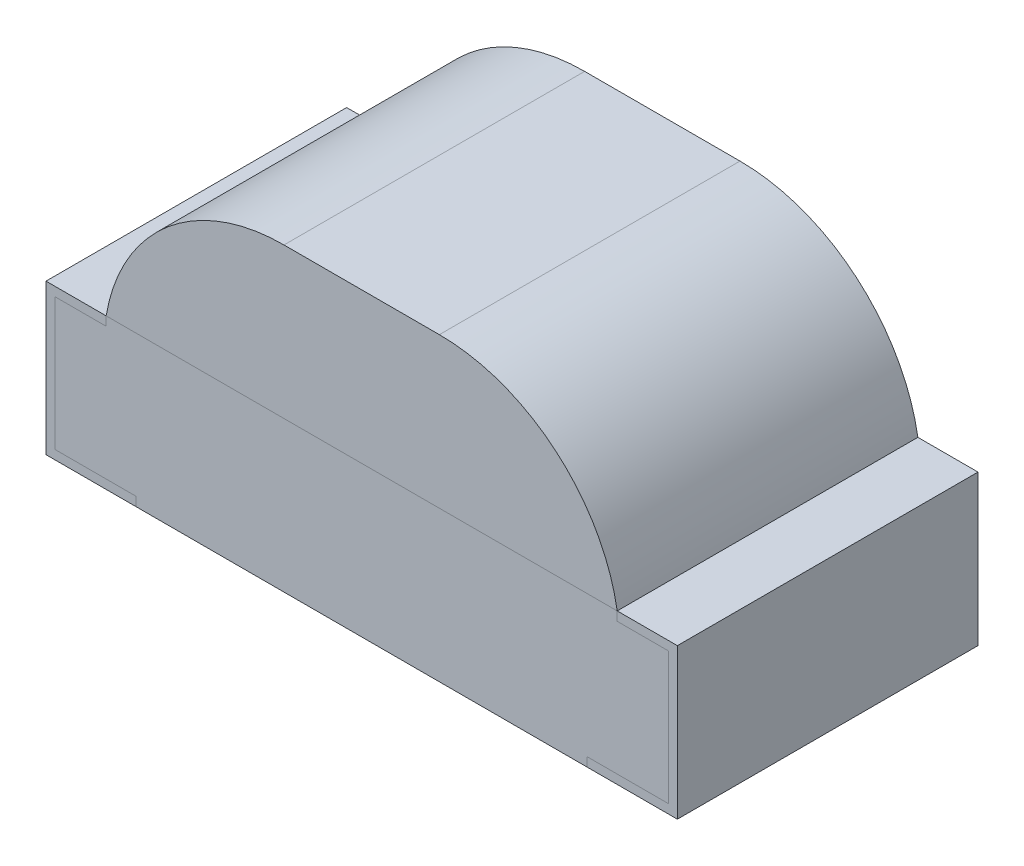
from build123d import *

# Parameters (mm, degrees)
EXTRUDE1_DEPTH     = 0.5
EXTRUDE3_DEPTH     = 0.5
EXTRUDE3_2_DEPTH   = 0.5
EXTRUDE6_DEPTH     = 0.5
SKETCH6_W          = 0.013291139
SKETCH6_H          = 0.012658227
SKETCH6_H_2        = 0.012658228
CUT_EXTRUDE1_DEPTH = 0.01


with BuildPart() as part:
    # Sketch1 → Extrude1 (new body, symmetric)
    with BuildSketch(Plane.XY):
        Polygon((0.85, 0.25), (-0.85, 0.25), (-0.85, 0.22), (-1.02, 0.22), (-1.02, -0.22), (-0.75, -0.22), (-0.75, -0.25), (0.75, -0.25), (0.75, -0.22), (1.02, -0.22), (1.02, 0.22), (0.85, 0.22), align=None)
    extrude(amount=EXTRUDE1_DEPTH, both=True)


with BuildPart() as body_2:
    # Sketch1_6 → Extrude3 (new body, symmetric)
    with BuildSketch(Plane.XY):
        Polygon((-0.85, 0.25), (-1.05, 0.25), (-1.05, -0.25), (-0.75, -0.25), (-0.75, -0.22), (-1.02, -0.22), (-1.02, 0.22), (-0.85, 0.22), align=None)
    extrude(amount=EXTRUDE3_DEPTH, both=True)


with BuildPart() as body_3:
    # Sketch1_6 → Extrude3 2 (new body, symmetric)
    with BuildSketch(Plane.XY):
        Polygon((1.05, 0.25), (0.85, 0.25), (0.85, 0.22), (1.02, 0.22), (1.02, -0.22), (0.75, -0.22), (0.75, -0.25), (1.05, -0.25), align=None)
    extrude(amount=EXTRUDE3_2_DEPTH, both=True)

    # Sketch6 → Cut-Extrude1 (cut)
    with BuildSketch(Plane.XZ.offset(0.25)):
        Polygon((0.942023927, -0.286075949), (0.979365699, -0.297804589), (0.979365699, -0.310176028), (0.954197582, -0.318384098), (0.979365699, -0.326147152), (0.979365699, -0.339013054), (0.942023927, -0.350632911), (0.942023927, -0.338043908), (0.96776562, -0.331546677), (0.942023927, -0.323338608), (0.942023927, -0.312589003), (0.96776562, -0.30443038), (0.942023927, -0.298022152), align=None)
        Polygon((0.942023927, -0.218987342), (0.979365699, -0.230715981), (0.979365699, -0.243087421), (0.954197582, -0.251295491), (0.979365699, -0.259058544), (0.979365699, -0.271924446), (0.942023927, -0.283544304), (0.942023927, -0.270955301), (0.96776562, -0.26445807), (0.942023927, -0.25625), (0.942023927, -0.245500396), (0.96776562, -0.237341772), (0.942023927, -0.230933544), align=None)
        Polygon((0.942023927, -0.151898734), (0.979365699, -0.163627373), (0.979365699, -0.175998813), (0.954197582, -0.184206883), (0.979365699, -0.191969937), (0.979365699, -0.204835839), (0.942023927, -0.216455696), (0.942023927, -0.203866693), (0.96776562, -0.197369462), (0.942023927, -0.189161392), (0.942023927, -0.178411788), (0.96776562, -0.170253165), (0.942023927, -0.163844937), align=None)
        with Locations((0.97272013, -0.137974684)):
            Rectangle(SKETCH6_W, SKETCH6_H)
        with BuildLine():
            add(Edge.make_bspline(
                [(0.963780256, -0.079746835), (0.964391317, -0.079765095), (0.965591237, -0.07980095), (0.967345165, -0.080105597), (0.969007007, -0.080603118), (0.970587626, -0.081286176), (0.972069839, -0.082190859), (0.973467847, -0.083281511), (0.974774946, -0.084575265), (0.97597921, -0.086053455), (0.977081541, -0.087694003), (0.978027094, -0.089495243), (0.978840362, -0.091429741), (0.97950595, -0.093506939), (0.980001407, -0.095729674), (0.980363044, -0.098088578), (0.980599804, -0.100585248), (0.980620774, -0.102297042), (0.980631522, -0.103174446)],
                knots=[0, 0, 0, 0, 0.907462679, 1.781953809, 2.635804048, 3.480274448, 4.332887508, 5.208817748, 6.109340518, 7.059474472, 8.037577805, 9.041105121, 10.077237313, 11.152245627, 12.27748741, 13.457227022, 14.696666784, 16, 16, 16, 16], degree=3))
            add(Edge.make_bspline(
                [(0.980631522, -0.103174446), (0.98061789, -0.104183438), (0.980591488, -0.106137532), (0.980398801, -0.108971316), (0.980054827, -0.111603049), (0.979576536, -0.114051922), (0.978974894, -0.116354073), (0.978329572, -0.118570745), (0.977597282, -0.120711391), (0.977047213, -0.122097937), (0.976774718, -0.12278481)],
                knots=[0, 0, 0, 0, 1.203182053, 2.33017619, 3.384818652, 4.366208123, 5.30340534, 6.221361684, 7.118890722, 8, 8, 8, 8], degree=3))
            Line((0.976774718, -0.12278481), (0.964808737, -0.12278481))
            Line((0.964808737, -0.12278481), (0.964808737, -0.121360759))
            add(Edge.make_bspline(
                [(0.964808737, -0.121360759), (0.965349219, -0.120677978), (0.966427008, -0.119316423), (0.967811185, -0.117102944), (0.968997691, -0.114773438), (0.969989002, -0.112354241), (0.970776809, -0.109903557), (0.971340262, -0.107469023), (0.971709944, -0.105084532), (0.971750725, -0.103505371), (0.971770763, -0.10272943)],
                knots=[0, 0, 0, 0, 1.030738938, 2.055426519, 3.085610749, 4.123842265, 5.148648843, 6.130724483, 7.081507926, 8, 8, 8, 8], degree=3))
            add(Edge.make_bspline(
                [(0.971770763, -0.10272943), (0.971770095, -0.102515059), (0.971768664, -0.102056106), (0.971708608, -0.101324778), (0.971643408, -0.100500017), (0.971546409, -0.099612821), (0.971429223, -0.098716237), (0.971258632, -0.097882287), (0.971072578, -0.097128904), (0.970889029, -0.096675553), (0.970801617, -0.096459652)],
                knots=[0, 0, 0, 0, 0.806557331, 1.726776592, 2.760222249, 3.920734434, 5.085813889, 6.161303184, 7.124353598, 8, 8, 8, 8], degree=3))
            add(Edge.make_bspline(
                [(0.970801617, -0.096459652), (0.970687341, -0.096220023), (0.970462763, -0.095749102), (0.970059431, -0.095098444), (0.969606025, -0.094520783), (0.969125331, -0.09399241), (0.968550008, -0.093549248), (0.967846406, -0.093240817), (0.967022414, -0.093067634), (0.966434735, -0.093048233), (0.966124006, -0.093037975)],
                knots=[0, 0, 0, 0, 1.025060442, 2.01446193, 2.949256246, 3.85908539, 4.768290539, 5.73153362, 6.800575992, 8, 8, 8, 8], degree=3))
            add(Edge.make_bspline(
                [(0.966124006, -0.093037975), (0.965851203, -0.093053907), (0.96531479, -0.093085234), (0.964547015, -0.093373687), (0.963843309, -0.093828987), (0.963206604, -0.094465973), (0.962647468, -0.095272368), (0.962136146, -0.096231159), (0.961721689, -0.097366685), (0.961502393, -0.098185091), (0.96138706, -0.098615506)],
                knots=[0, 0, 0, 0, 0.825786558, 1.623739628, 2.456775365, 3.355767579, 4.339087636, 5.42728423, 6.646958453, 8, 8, 8, 8], degree=3))
            add(Edge.make_bspline(
                [(0.96138706, -0.098615506), (0.961164205, -0.099600075), (0.960706836, -0.101620729), (0.960117289, -0.104691497), (0.959499962, -0.107759915), (0.958894253, -0.109735067), (0.958598294, -0.110700158)],
                knots=[0, 0, 0, 0, 0.976116373, 2.003306214, 3.02438349, 4, 4, 4, 4], degree=3))
            add(Edge.make_bspline(
                [(0.958598294, -0.110700158), (0.958421434, -0.111219236), (0.958077159, -0.112229669), (0.957500818, -0.113679248), (0.956848312, -0.11500093), (0.956187082, -0.116229502), (0.955447781, -0.117326516), (0.954677409, -0.118323373), (0.95385793, -0.119209525), (0.952979238, -0.11997228), (0.952061704, -0.120644504), (0.951087596, -0.121220017), (0.950056938, -0.121704075), (0.948974709, -0.122100291), (0.947840079, -0.122409707), (0.946651444, -0.122619779), (0.945409819, -0.122769127), (0.944562635, -0.122779511), (0.944130335, -0.12278481)],
                knots=[0, 0, 0, 0, 1.287139616, 2.505537848, 3.65787682, 4.745319116, 5.777517297, 6.75878323, 7.700384896, 8.605120322, 9.485712598, 10.366814604, 11.256335458, 12.154696155, 13.068779358, 14.012730507, 14.985940713, 16, 16, 16, 16], degree=3))
            add(Edge.make_bspline(
                [(0.944130335, -0.12278481), (0.943552262, -0.12276616), (0.942414625, -0.122729457), (0.940750114, -0.122428732), (0.939175704, -0.121915476), (0.937674126, -0.121222297), (0.936266995, -0.12030855), (0.934928251, -0.119212489), (0.933682003, -0.117907334), (0.932532685, -0.11641467), (0.931493282, -0.114771246), (0.930574929, -0.113004244), (0.929821705, -0.111114818), (0.929181089, -0.109124876), (0.928704892, -0.107015179), (0.928345103, -0.104796694), (0.928138602, -0.102459763), (0.928112965, -0.100864057), (0.928099877, -0.100049446)],
                knots=[0, 0, 0, 0, 0.894901293, 1.761149761, 2.608783409, 3.453876344, 4.314933854, 5.200038827, 6.12799933, 7.103249695, 8.113098521, 9.136064399, 10.182719798, 11.259667356, 12.370545059, 13.528828137, 14.738461593, 16, 16, 16, 16], degree=3))
            add(Edge.make_bspline(
                [(0.928099877, -0.100049446), (0.928111054, -0.099215117), (0.928133389, -0.097547873), (0.92832116, -0.095056937), (0.92860296, -0.092581272), (0.929006451, -0.090146191), (0.929511182, -0.087804125), (0.930055906, -0.085592886), (0.930675869, -0.083553353), (0.93115292, -0.082266497), (0.931383104, -0.08164557)],
                knots=[0, 0, 0, 0, 1.065384654, 2.128962885, 3.18847586, 4.246683315, 5.279600907, 6.247539799, 7.154412252, 8, 8, 8, 8], degree=3))
            Line((0.931383104, -0.08164557), (0.942656839, -0.08164557))
            Line((0.942656839, -0.08164557), (0.942656839, -0.083059731))
            add(Edge.make_bspline(
                [(0.942656839, -0.083059731), (0.942257266, -0.08359651), (0.941441829, -0.084691955), (0.940389812, -0.086516316), (0.939423961, -0.088503046), (0.938559296, -0.090636887), (0.93784973, -0.092873533), (0.937335013, -0.095162206), (0.937015502, -0.097475764), (0.936978929, -0.099026556), (0.936960636, -0.099802215)],
                knots=[0, 0, 0, 0, 0.892231706, 1.82084296, 2.804411717, 3.838445872, 4.890103822, 5.931567007, 6.965432763, 8, 8, 8, 8], degree=3))
            add(Edge.make_bspline(
                [(0.936960636, -0.099802215), (0.93697296, -0.100349834), (0.936997673, -0.101447923), (0.937169413, -0.103085623), (0.937509265, -0.10470221), (0.937914818, -0.105720746), (0.938117677, -0.106230222)],
                knots=[0, 0, 0, 0, 0.99896713, 2.003134239, 3.001159596, 4, 4, 4, 4], degree=3))
            add(Edge.make_bspline(
                [(0.938117677, -0.106230222), (0.938218275, -0.106447074), (0.938419402, -0.106880635), (0.938809098, -0.107484586), (0.939267718, -0.108044383), (0.93979435, -0.108546656), (0.940384884, -0.108958725), (0.941016219, -0.109279365), (0.941697686, -0.109459079), (0.942164706, -0.109482091), (0.942399718, -0.109493671)],
                knots=[0, 0, 0, 0, 1.005120364, 2.009570296, 3.014977851, 4.045438181, 5.061509448, 6.035608779, 7.011484765, 8, 8, 8, 8], degree=3))
            add(Edge.make_bspline(
                [(0.942399718, -0.109493671), (0.942718684, -0.109476274), (0.943328198, -0.109443029), (0.944185046, -0.109143031), (0.944916602, -0.108644196), (0.945413099, -0.108067647), (0.945762478, -0.107509157), (0.946015098, -0.106988898), (0.94627181, -0.106389173), (0.946516408, -0.105700449), (0.946763431, -0.104932881), (0.947000766, -0.10407842), (0.947225546, -0.103137116), (0.947368622, -0.102479171), (0.947443231, -0.102136076)],
                knots=[0, 0, 0, 0, 1.174343879, 2.244064321, 3.303704314, 4.407076671, 5.02483983, 5.732197225, 6.53898402, 7.431906431, 8.428480183, 9.514816237, 10.704066255, 12, 12, 12, 12], degree=3))
            add(Edge.make_bspline(
                [(0.947443231, -0.102136076), (0.947631281, -0.101219696), (0.94800011, -0.099422374), (0.948551726, -0.096720829), (0.949203157, -0.093973178), (0.949769353, -0.092134993), (0.95006388, -0.091178797)],
                knots=[0, 0, 0, 0, 0.995794372, 1.953081347, 2.935223864, 4, 4, 4, 4], degree=3))
            add(Edge.make_bspline(
                [(0.95006388, -0.091178797), (0.950223558, -0.090705552), (0.950535914, -0.089779808), (0.951078274, -0.088459051), (0.951669256, -0.087234467), (0.952280719, -0.086095531), (0.952961565, -0.085063797), (0.95367023, -0.084121379), (0.954423217, -0.083272798), (0.955230894, -0.082528232), (0.956086232, -0.081864231), (0.957011058, -0.081306729), (0.95798564, -0.080813421), (0.959025857, -0.080417612), (0.960131338, -0.080125373), (0.96129478, -0.079909034), (0.962517356, -0.079763429), (0.963354591, -0.079752429), (0.963780256, -0.079746835)],
                knots=[0, 0, 0, 0, 1.237247399, 2.420255609, 3.534416354, 4.605351393, 5.620193117, 6.593738998, 7.524982051, 8.426564095, 9.311945829, 10.20281032, 11.097671666, 12.01534975, 12.954438892, 13.926750701, 14.945921247, 16, 16, 16, 16], degree=3))
        make_face()
        with BuildLine():
            Line((0.979365699, -0.033544304), (0.979365699, -0.04556962))
            Line((0.979365699, -0.04556962), (0.97544956, -0.04556962))
            add(Edge.make_bspline(
                [(0.97544956, -0.04556962), (0.975854012, -0.046116191), (0.976633789, -0.047169971), (0.977671595, -0.048757603), (0.978567758, -0.050268087), (0.97932077, -0.051737301), (0.979934597, -0.053237003), (0.980340675, -0.054854082), (0.980592715, -0.056604595), (0.980618299, -0.057818171), (0.980631522, -0.058445411)],
                knots=[0, 0, 0, 0, 1.15097647, 2.219065785, 3.209751872, 4.123278731, 5.012494873, 5.946522673, 6.938654008, 8, 8, 8, 8], degree=3))
            add(Edge.make_bspline(
                [(0.980631522, -0.058445411), (0.980620043, -0.058953546), (0.98059769, -0.05994303), (0.9804269, -0.061382224), (0.980152449, -0.06273305), (0.979769108, -0.063998021), (0.979263402, -0.065173533), (0.978638053, -0.066252373), (0.977907119, -0.067245707), (0.977068992, -0.068147533), (0.976108418, -0.068942805), (0.975047068, -0.069636341), (0.973879742, -0.070224244), (0.972604061, -0.070695064), (0.971224838, -0.07107253), (0.969735235, -0.071334519), (0.968141665, -0.071494809), (0.967044101, -0.071510779), (0.966480019, -0.071518987)],
                knots=[0, 0, 0, 0, 1.108887696, 2.159324556, 3.158383213, 4.114277414, 5.039206009, 5.945047284, 6.830075132, 7.726032535, 8.625162295, 9.545152215, 10.487958828, 11.471559655, 12.508379831, 13.604991163, 14.769110247, 16, 16, 16, 16], degree=3))
            Line((0.966480019, -0.071518987), (0.942023927, -0.071518987))
            Line((0.942023927, -0.071518987), (0.942023927, -0.059493671))
            Line((0.942023927, -0.059493671), (0.960813484, -0.059493671))
            add(Edge.make_bspline(
                [(0.960813484, -0.059493671), (0.96127172, -0.059492853), (0.962148828, -0.059491288), (0.963401731, -0.059450118), (0.964535817, -0.059389668), (0.965556831, -0.059320316), (0.966480207, -0.059193807), (0.967313287, -0.059004953), (0.968073088, -0.05876954), (0.968526439, -0.058537381), (0.968744655, -0.058425633)],
                knots=[0, 0, 0, 0, 1.361401701, 2.605856924, 3.723918663, 4.735739235, 5.645738665, 6.489217889, 7.27279937, 8, 8, 8, 8], degree=3))
            add(Edge.make_bspline(
                [(0.968744655, -0.058425633), (0.968943974, -0.058310612), (0.969335819, -0.058084491), (0.969839459, -0.057624598), (0.970257655, -0.057086557), (0.970595005, -0.056451936), (0.970832585, -0.055703876), (0.971026175, -0.054841422), (0.971111284, -0.053845226), (0.971128655, -0.053141541), (0.971137851, -0.052768987)],
                knots=[0, 0, 0, 0, 0.848923305, 1.668910138, 2.502822694, 3.358979167, 4.311113223, 5.396624103, 6.621686681, 8, 8, 8, 8], degree=3))
            add(Edge.make_bspline(
                [(0.971137851, -0.052768987), (0.971127877, -0.052498527), (0.971107384, -0.051942841), (0.971012868, -0.051087147), (0.970810789, -0.050196327), (0.970488804, -0.04893715), (0.969895322, -0.047349804), (0.969216559, -0.046167616), (0.968873215, -0.04556962)],
                knots=[0, 0, 0, 0, 0.638098464, 1.31103257, 2.025970928, 2.789492669, 4.376004971, 6, 6, 6, 6], degree=3))
            Line((0.968873215, -0.04556962), (0.942023927, -0.04556962))
            Line((0.942023927, -0.04556962), (0.942023927, -0.033544304))
            Line((0.942023927, -0.033544304), (0.979365699, -0.033544304))
        make_face()
        with BuildLine():
            Line((0.979365699, 0.015189873), (0.979365699, 0.003164557))
            Line((0.979365699, 0.003164557), (0.960576142, 0.003164557))
            add(Edge.make_bspline(
                [(0.960576142, 0.003164557), (0.959810931, 0.003154152), (0.958281489, 0.003133354), (0.956402788, 0.002969251), (0.954979251, 0.002799515), (0.954064375, 0.002612137), (0.953290217, 0.002396966), (0.952847347, 0.002190751), (0.952644972, 0.002096519)],
                knots=[0, 0, 0, 0, 1.709225407, 3.416259723, 4.21101956, 4.910102269, 5.501957085, 6, 6, 6, 6], degree=3))
            add(Edge.make_bspline(
                [(0.952644972, 0.002096519), (0.952445906, 0.001974306), (0.952055609, 0.001734689), (0.951549666, 0.001265768), (0.951131294, 0.000717495), (0.95079987, 7.7929e-05), (0.950552666, -0.000662865), (0.950379525, -0.00152278), (0.950273413, -0.002512547), (0.950259263, -0.00321701), (0.950251775, -0.003589794)],
                knots=[0, 0, 0, 0, 0.860284341, 1.686708632, 2.528476982, 3.393563585, 4.332150703, 5.400907339, 6.624626855, 8, 8, 8, 8], degree=3))
            add(Edge.make_bspline(
                [(0.950251775, -0.003589794), (0.950281748, -0.004155273), (0.95034291, -0.005309189), (0.950677276, -0.006746396), (0.951103891, -0.007903214), (0.951486848, -0.008828607), (0.951965498, -0.009786415), (0.952328843, -0.010428192), (0.952516411, -0.010759494)],
                knots=[0, 0, 0, 0, 1.338233385, 2.730803257, 3.468495571, 4.255080394, 5.099229486, 6, 6, 6, 6], degree=3))
            Line((0.952516411, -0.010759494), (0.979365699, -0.010759494))
            Line((0.979365699, -0.010759494), (0.979365699, -0.02278481))
            Line((0.979365699, -0.02278481), (0.942023927, -0.02278481))
            Line((0.942023927, -0.02278481), (0.942023927, -0.010759494))
            Line((0.942023927, -0.010759494), (0.945940066, -0.010759494))
            add(Edge.make_bspline(
                [(0.945940066, -0.010759494), (0.945536848, -0.010230875), (0.944751958, -0.009201887), (0.943735253, -0.007613511), (0.942830325, -0.006078155), (0.942074258, -0.004550894), (0.941474958, -0.002988645), (0.941067156, -0.00135483), (0.940795682, 0.000353526), (0.940770776, 0.001521863), (0.940758104, 0.002116297)],
                knots=[0, 0, 0, 0, 1.126064518, 2.191951536, 3.19307265, 4.144813015, 5.076393104, 6.021983703, 6.993610568, 8, 8, 8, 8], degree=3))
            add(Edge.make_bspline(
                [(0.940758104, 0.002116297), (0.940770805, 0.00261443), (0.940795598, 0.003586873), (0.940950374, 0.005004298), (0.941225985, 0.006339851), (0.941623913, 0.007586544), (0.942119593, 0.008754385), (0.942721581, 0.009841227), (0.94345323, 0.010834129), (0.944283169, 0.011748289), (0.945228932, 0.012567521), (0.946293178, 0.013267202), (0.947464422, 0.013865138), (0.948739194, 0.014358798), (0.950128673, 0.014734317), (0.951625363, 0.014992409), (0.953230812, 0.015169548), (0.954338815, 0.015182963), (0.954909608, 0.015189873)],
                knots=[0, 0, 0, 0, 1.088244909, 2.124447647, 3.110254678, 4.062235362, 4.978491991, 5.877983887, 6.769571508, 7.666696544, 8.570415953, 9.495151274, 10.442024977, 11.43832337, 12.476026402, 13.580659577, 14.753665747, 16, 16, 16, 16], degree=3))
            Line((0.954909608, 0.015189873), (0.979365699, 0.015189873))
        make_face()
        Polygon((0.979365699, 0.062658228), (0.979365699, 0.026582278), (0.929365699, 0.026582278), (0.929365699, 0.039240506), (0.969872029, 0.039240506), (0.969872029, 0.062658228), align=None)
        Polygon((0.979365699, 0.106329114), (0.979365699, 0.070253165), (0.929365699, 0.070253165), (0.929365699, 0.106329114), (0.93885937, 0.106329114), (0.93885937, 0.082911392), (0.94772013, 0.082911392), (0.94772013, 0.10443038), (0.957213801, 0.10443038), (0.957213801, 0.082911392), (0.969872029, 0.082911392), (0.969872029, 0.106329114), align=None)
        with BuildLine():
            add(Edge.make_bspline(
                [(0.954415146, 0.164556962), (0.95498899, 0.164547304), (0.956125433, 0.164528178), (0.957807836, 0.164380583), (0.959440674, 0.16411757), (0.961032798, 0.163777979), (0.962572262, 0.163316726), (0.964076051, 0.16277587), (0.965528798, 0.162121047), (0.966929515, 0.16136862), (0.968265566, 0.160543884), (0.969525671, 0.15965651), (0.97071728, 0.15873362), (0.971814726, 0.157738964), (0.972835736, 0.156699373), (0.973781143, 0.155611609), (0.974632859, 0.154459076), (0.975144301, 0.153655495), (0.975400114, 0.15325356)],
                knots=[0, 0, 0, 0, 1.105570398, 2.18947457, 3.250358341, 4.290584537, 5.323553275, 6.344225964, 7.367641686, 8.3905646, 9.405808457, 10.390761353, 11.358902336, 12.307789878, 13.241960776, 14.165076779, 15.082208636, 16, 16, 16, 16], degree=3))
            add(Edge.make_bspline(
                [(0.975400114, 0.15325356), (0.975756289, 0.15263397), (0.976470457, 0.151391629), (0.977303153, 0.149399346), (0.978012171, 0.147335712), (0.978515776, 0.145152055), (0.978901516, 0.14283301), (0.979176757, 0.140333989), (0.979328806, 0.137633765), (0.979353121, 0.135766275), (0.979365699, 0.134800237)],
                knots=[0, 0, 0, 0, 0.896331627, 1.797236794, 2.705411718, 3.632841792, 4.606367508, 5.655603524, 6.787262262, 8, 8, 8, 8], degree=3))
            Line((0.979365699, 0.134800237), (0.979365699, 0.117088608))
            Line((0.979365699, 0.117088608), (0.929365699, 0.117088608))
            Line((0.929365699, 0.117088608), (0.929365699, 0.135304589))
            add(Edge.make_bspline(
                [(0.929365699, 0.135304589), (0.929374147, 0.136293933), (0.92939044, 0.138202255), (0.929597095, 0.140957702), (0.929901305, 0.14350546), (0.93034931, 0.145849866), (0.930903253, 0.148005294), (0.931599487, 0.149966708), (0.93234558, 0.151774882), (0.932982883, 0.152864142), (0.933291728, 0.153392009)],
                knots=[0, 0, 0, 0, 1.267100211, 2.444079055, 3.537724964, 4.552266402, 5.499704501, 6.385138932, 7.217420793, 8, 8, 8, 8], degree=3))
            add(Edge.make_bspline(
                [(0.933291728, 0.153392009), (0.933559998, 0.153817486), (0.934093455, 0.154663548), (0.934984381, 0.155864156), (0.93596242, 0.156978869), (0.936988329, 0.158043121), (0.938089773, 0.159033028), (0.939259125, 0.159954635), (0.940498178, 0.160806518), (0.941802888, 0.161585596), (0.943168008, 0.162295638), (0.94460418, 0.162891678), (0.946095617, 0.163411359), (0.947645087, 0.1638344), (0.949253782, 0.164162565), (0.950922522, 0.164385607), (0.952649116, 0.164527324), (0.953821513, 0.164546999), (0.954415146, 0.164556962)],
                knots=[0, 0, 0, 0, 0.964043478, 1.917004671, 2.862223898, 3.805158963, 4.749279098, 5.698713747, 6.657523689, 7.629652222, 8.610369353, 9.604453025, 10.607693792, 11.636365947, 12.681120053, 13.752669011, 14.862083412, 16, 16, 16, 16], degree=3))
        make_face()
        with BuildLine():
            add(Edge.make_bspline(
                [(0.954336032, 0.151265823), (0.953547104, 0.151242622), (0.95202427, 0.151197838), (0.949822169, 0.150866066), (0.947805536, 0.150276301), (0.946247285, 0.149611683), (0.945110777, 0.14894241), (0.944311611, 0.148378763), (0.94355452, 0.1477539), (0.942850098, 0.147058603), (0.94219658, 0.146291009), (0.941582125, 0.14546038), (0.941017802, 0.14456036), (0.940687799, 0.143923844), (0.940520763, 0.143601661)],
                knots=[0, 0, 0, 0, 1.694561208, 3.270940604, 4.767926833, 6.198032689, 6.896357436, 7.597727349, 8.296769799, 9.00280713, 9.720956486, 10.460265288, 11.220639329, 12, 12, 12, 12], degree=3))
            add(Edge.make_bspline(
                [(0.940520763, 0.143601661), (0.940367506, 0.143264194), (0.940063739, 0.14259531), (0.939696696, 0.141560172), (0.939415532, 0.140513821), (0.939179321, 0.139416708), (0.939040753, 0.138178328), (0.938934415, 0.136717082), (0.938865951, 0.134988745), (0.938861666, 0.133745448), (0.93885937, 0.133079509)],
                knots=[0, 0, 0, 0, 0.826913061, 1.638999358, 2.447478739, 3.243919028, 4.140906711, 5.225381046, 6.513851968, 8, 8, 8, 8], degree=3))
            Line((0.93885937, 0.133079509), (0.93885937, 0.129746835))
            Line((0.93885937, 0.129746835), (0.969872029, 0.129746835))
            Line((0.969872029, 0.129746835), (0.969872029, 0.133079509))
            add(Edge.make_bspline(
                [(0.969872029, 0.133079509), (0.969869508, 0.133458605), (0.969864641, 0.134190473), (0.969845064, 0.135248697), (0.96981499, 0.136231088), (0.969778791, 0.137134731), (0.969722466, 0.137959632), (0.969635471, 0.138703229), (0.969567122, 0.139371634), (0.96942856, 0.140157893), (0.969225436, 0.141085478), (0.968883901, 0.142168875), (0.968459102, 0.143239224), (0.968116564, 0.143933499), (0.967943627, 0.144284019)],
                knots=[0, 0, 0, 0, 1.186788252, 2.291168447, 3.31326867, 4.263560303, 5.122314491, 5.900668105, 6.60723418, 7.224768558, 8.398927205, 9.577205322, 10.776800932, 12, 12, 12, 12], degree=3))
            add(Edge.make_bspline(
                [(0.967943627, 0.144284019), (0.967771888, 0.144575875), (0.967434144, 0.145149841), (0.966881224, 0.14597193), (0.966263682, 0.146715236), (0.965622287, 0.1474185), (0.964926497, 0.14804408), (0.964204727, 0.148632729), (0.963417456, 0.14912535), (0.962322988, 0.149749785), (0.96080941, 0.150371573), (0.958823448, 0.15088838), (0.956643871, 0.151207776), (0.955125018, 0.151245978), (0.954336032, 0.151265823)],
                knots=[0, 0, 0, 0, 0.755184287, 1.485151634, 2.206180267, 2.908413556, 3.605665444, 4.291074465, 4.982332562, 5.673512475, 7.100235687, 8.614142391, 10.24117603, 12, 12, 12, 12], degree=3))
        make_face(mode=Mode.SUBTRACT)
        with Locations((0.97272013, 0.180379747)):
            Rectangle(SKETCH6_W, SKETCH6_H_2)
        with BuildLine():
            add(Edge.make_bspline(
                [(0.980631522, 0.217701741), (0.980620613, 0.216906686), (0.9805992, 0.215346121), (0.980360794, 0.213060425), (0.980001758, 0.210877928), (0.97949197, 0.208804458), (0.978817283, 0.206852816), (0.977999747, 0.205016624), (0.976999828, 0.20331702), (0.976208519, 0.202283529), (0.975815462, 0.201770174)],
                knots=[0, 0, 0, 0, 1.123640227, 2.2055255, 3.245221982, 4.248949655, 5.220213072, 6.160941522, 7.086505793, 8, 8, 8, 8], degree=3))
            add(Edge.make_bspline(
                [(0.975815462, 0.201770174), (0.975388046, 0.201294357), (0.974534865, 0.200344562), (0.973049594, 0.199110748), (0.971405107, 0.19805171), (0.969609281, 0.197145583), (0.967649338, 0.196429607), (0.965524391, 0.195933339), (0.963245726, 0.195619537), (0.961671624, 0.195586562), (0.96086293, 0.19556962)],
                knots=[0, 0, 0, 0, 0.916342154, 1.829140869, 2.758848968, 3.716597128, 4.708179637, 5.743612459, 6.840783343, 8, 8, 8, 8], degree=3))
            add(Edge.make_bspline(
                [(0.96086293, 0.19556962), (0.960011317, 0.195589), (0.958360777, 0.195626562), (0.955974683, 0.195958442), (0.953765843, 0.196493248), (0.951739889, 0.197262027), (0.949893293, 0.198227248), (0.948207375, 0.199359494), (0.946685913, 0.200669757), (0.945813194, 0.201673326), (0.94537638, 0.202175633)],
                knots=[0, 0, 0, 0, 1.171797512, 2.271099083, 3.308930235, 4.294129479, 5.24602549, 6.17106565, 7.084581485, 8, 8, 8, 8], degree=3))
            add(Edge.make_bspline(
                [(0.94537638, 0.202175633), (0.944992053, 0.202688547), (0.944218757, 0.203720569), (0.943270397, 0.205420009), (0.942471414, 0.207228345), (0.941833934, 0.209139987), (0.941359311, 0.211131338), (0.941011428, 0.213166058), (0.940797357, 0.215238016), (0.940771252, 0.216633199), (0.940758104, 0.217335839)],
                knots=[0, 0, 0, 0, 0.952013349, 1.915525331, 2.885385798, 3.888123097, 4.906830296, 5.926067872, 6.955529031, 8, 8, 8, 8], degree=3))
            add(Edge.make_bspline(
                [(0.940758104, 0.217335839), (0.940766284, 0.217959245), (0.940782367, 0.219185073), (0.940947946, 0.220984436), (0.941197454, 0.222710434), (0.94156924, 0.22436008), (0.942030647, 0.225943178), (0.942542721, 0.227474903), (0.943112676, 0.228957022), (0.943554654, 0.229907399), (0.943774323, 0.230379747)],
                knots=[0, 0, 0, 0, 1.107572103, 2.177862056, 3.208491727, 4.204802822, 5.180069889, 6.137814326, 7.074472616, 8, 8, 8, 8], degree=3))
            Line((0.943774323, 0.230379747), (0.954049244, 0.230379747))
            Line((0.954049244, 0.230379747), (0.954049244, 0.228708465))
            add(Edge.make_bspline(
                [(0.954049244, 0.228708465), (0.953840798, 0.228458567), (0.95338733, 0.227914921), (0.952673887, 0.227024009), (0.951913254, 0.225946553), (0.951468921, 0.225124219), (0.95123081, 0.224683544)],
                knots=[0, 0, 0, 0, 0.792806788, 1.724728901, 2.780722718, 4, 4, 4, 4], degree=3))
            add(Edge.make_bspline(
                [(0.95123081, 0.224683544), (0.951011038, 0.224219215), (0.950558792, 0.223263722), (0.95012665, 0.221990162), (0.949858659, 0.22089), (0.949727647, 0.219986025), (0.949633839, 0.21901897), (0.949623947, 0.218351384), (0.949618864, 0.218008307)],
                knots=[0, 0, 0, 0, 1.332411269, 2.741822805, 3.48048496, 4.268099981, 5.109965479, 6, 6, 6, 6], degree=3))
            add(Edge.make_bspline(
                [(0.949618864, 0.218008307), (0.949628534, 0.217625491), (0.949647275, 0.216883611), (0.949787231, 0.21580338), (0.950021518, 0.21479124), (0.950359639, 0.213846625), (0.950789792, 0.212969345), (0.951299872, 0.21215151), (0.951925867, 0.211413689), (0.952635083, 0.210742876), (0.953430245, 0.21014909), (0.954293514, 0.209635725), (0.955222454, 0.209194359), (0.95622141, 0.208843413), (0.95728634, 0.208564658), (0.958417745, 0.208369875), (0.959617544, 0.208248986), (0.960440692, 0.208235015), (0.96086293, 0.208227848)],
                knots=[0, 0, 0, 0, 1.087164589, 2.106874378, 3.088024391, 4.032801718, 4.949890679, 5.859058447, 6.763003849, 7.690312844, 8.626654282, 9.575690722, 10.539030902, 11.54301425, 12.578634972, 13.662366762, 14.800897888, 16, 16, 16, 16], degree=3))
            add(Edge.make_bspline(
                [(0.96086293, 0.208227848), (0.961295009, 0.208235235), (0.962134515, 0.208249588), (0.96335532, 0.208366345), (0.964496036, 0.208574291), (0.965558696, 0.208859915), (0.966541705, 0.209222089), (0.967440403, 0.209674648), (0.968268807, 0.210192826), (0.969000113, 0.210815105), (0.969658274, 0.211497047), (0.970226341, 0.212254492), (0.970700413, 0.213084112), (0.971102645, 0.213975202), (0.971391844, 0.214941723), (0.97161019, 0.215969991), (0.971754468, 0.217064769), (0.97176525, 0.217819945), (0.971770763, 0.218206092)],
                knots=[0, 0, 0, 0, 1.230336593, 2.390482092, 3.487897344, 4.52859895, 5.520747884, 6.465347575, 7.38981449, 8.296085817, 9.192433006, 10.084246191, 10.984321635, 11.908883871, 12.862027947, 13.850751296, 14.901019963, 16, 16, 16, 16], degree=3))
            add(Edge.make_bspline(
                [(0.971770763, 0.218206092), (0.971766335, 0.218568967), (0.971757704, 0.219276378), (0.971653983, 0.220306739), (0.971498788, 0.221281952), (0.971277972, 0.222198087), (0.971025373, 0.223053881), (0.970736774, 0.223834697), (0.970435452, 0.224541258), (0.970201545, 0.224971894), (0.970089592, 0.225178006)],
                knots=[0, 0, 0, 0, 1.201100869, 2.341500598, 3.425337164, 4.468451875, 5.459559168, 6.378110228, 7.223726512, 8, 8, 8, 8], degree=3))
            add(Edge.make_bspline(
                [(0.970089592, 0.225178006), (0.969875749, 0.225532184), (0.969464769, 0.226212871), (0.968754539, 0.22712543), (0.968051319, 0.227947493), (0.967572936, 0.228459546), (0.967340383, 0.228708465)],
                knots=[0, 0, 0, 0, 1.105932972, 2.12546697, 3.088749538, 4, 4, 4, 4], degree=3))
            Line((0.967340383, 0.228708465), (0.967340383, 0.230379747))
            Line((0.967340383, 0.230379747), (0.977694418, 0.230379747))
            add(Edge.make_bspline(
                [(0.977694418, 0.230379747), (0.977913189, 0.229907058), (0.978350784, 0.228961568), (0.978927359, 0.227504179), (0.979413799, 0.226007558), (0.979859972, 0.224481943), (0.980209069, 0.222897127), (0.980453684, 0.221238453), (0.980604554, 0.2194978), (0.98062241, 0.218308592), (0.980631522, 0.217701741)],
                knots=[0, 0, 0, 0, 0.952024047, 1.90427691, 2.862762905, 3.827874523, 4.80891974, 5.826446878, 6.890837857, 8, 8, 8, 8], degree=3))
        make_face()
        with BuildLine():
            add(Edge.make_bspline(
                [(0.960714592, 0.276582278), (0.961467008, 0.276569819), (0.962933668, 0.276545531), (0.965070078, 0.276277427), (0.967085299, 0.275865695), (0.968985718, 0.275299033), (0.970757241, 0.274540106), (0.972405218, 0.273618899), (0.973931309, 0.272532104), (0.975326422, 0.271286945), (0.976575518, 0.269886202), (0.977673615, 0.268349319), (0.978577139, 0.266664386), (0.979340414, 0.264860013), (0.979918464, 0.262915359), (0.980327439, 0.260835812), (0.980594605, 0.258627057), (0.980619011, 0.257107875), (0.980631522, 0.256329114)],
                knots=[0, 0, 0, 0, 1.120122129, 2.18341868, 3.201215738, 4.181270334, 5.131540819, 6.065757527, 6.988093576, 7.916512302, 8.844931028, 9.778115023, 10.722851943, 11.686686084, 12.691660064, 13.738321946, 14.84062285, 16, 16, 16, 16], degree=3))
            add(Edge.make_bspline(
                [(0.980631522, 0.256329114), (0.980619052, 0.25555034), (0.980594726, 0.254031131), (0.980326991, 0.251822563), (0.979920633, 0.249745454), (0.979336015, 0.247803128), (0.97857997, 0.245995972), (0.977673249, 0.244309059), (0.976575622, 0.242771968), (0.975326367, 0.241371367), (0.973931425, 0.240125848), (0.97240481, 0.239040346), (0.970759914, 0.238114876), (0.968981276, 0.23737468), (0.967087672, 0.236788414), (0.965069673, 0.236382025), (0.962933778, 0.236112366), (0.961467045, 0.236088297), (0.960714592, 0.236075949)],
                knots=[0, 0, 0, 0, 1.159424321, 2.261770074, 3.308474541, 4.308788811, 5.277191138, 6.221966496, 7.15518846, 8.08364496, 9.01210146, 9.934475036, 10.868729753, 11.817121636, 12.798654016, 13.816492484, 14.879832297, 16, 16, 16, 16], degree=3))
            add(Edge.make_bspline(
                [(0.960714592, 0.236075949), (0.959958875, 0.2360885), (0.958482361, 0.236113022), (0.956332988, 0.236380855), (0.95430244, 0.236789337), (0.952396164, 0.237372102), (0.950614926, 0.238125241), (0.948961832, 0.239048714), (0.947438445, 0.240146591), (0.946043363, 0.241401309), (0.944796099, 0.242807692), (0.943707046, 0.244351441), (0.94280265, 0.246033211), (0.942038767, 0.247833387), (0.941472494, 0.249777218), (0.941063417, 0.251845531), (0.940794462, 0.254044273), (0.940770444, 0.255553635), (0.940758104, 0.256329114)],
                knots=[0, 0, 0, 0, 1.123883205, 2.195836198, 3.217400301, 4.202580581, 5.156396106, 6.089661422, 7.013912723, 7.944661364, 8.875797629, 9.805201257, 10.748976071, 11.711828658, 12.709674189, 13.755270167, 14.846705509, 16, 16, 16, 16], degree=3))
            add(Edge.make_bspline(
                [(0.940758104, 0.256329114), (0.940770461, 0.257114486), (0.940794517, 0.258643574), (0.941062687, 0.260865238), (0.94146895, 0.262952303), (0.942052985, 0.264901108), (0.94280462, 0.266713112), (0.943732093, 0.2683867), (0.944819268, 0.269929179), (0.946084182, 0.271313311), (0.947481659, 0.27255519), (0.949010499, 0.273636368), (0.950664287, 0.274554106), (0.952445225, 0.275291978), (0.954341541, 0.275879079), (0.956358754, 0.276289285), (0.958496207, 0.276542361), (0.959962279, 0.276568741), (0.960714592, 0.276582278)],
                knots=[0, 0, 0, 0, 1.167473013, 2.273023816, 3.322954552, 4.326451713, 5.293391623, 6.234801871, 7.166614545, 8.093305908, 9.017100806, 9.942078766, 10.872536262, 11.824015763, 12.804065898, 13.820367293, 14.881523901, 16, 16, 16, 16], degree=3))
        make_face()
        with BuildLine():
            add(Edge.make_bspline(
                [(0.969961032, 0.261728639), (0.9697109, 0.261905927), (0.969201851, 0.262266729), (0.968352103, 0.262707456), (0.967431209, 0.263082611), (0.96641883, 0.26339303), (0.965273657, 0.26365043), (0.963948181, 0.263799725), (0.962430806, 0.263916501), (0.961354392, 0.263921435), (0.960783816, 0.263924051)],
                knots=[0, 0, 0, 0, 0.765135464, 1.557141201, 2.384449913, 3.246599353, 4.1996426, 5.311961702, 6.575150963, 8, 8, 8, 8], degree=3))
            add(Edge.make_bspline(
                [(0.960783816, 0.263924051), (0.96024638, 0.263915184), (0.959216709, 0.263898196), (0.957736777, 0.263805304), (0.956392028, 0.263629574), (0.955179674, 0.263382815), (0.954093639, 0.263079021), (0.953127474, 0.26271162), (0.952270497, 0.262294901), (0.951767936, 0.261952023), (0.951527487, 0.261787975)],
                knots=[0, 0, 0, 0, 1.337015307, 2.56157572, 3.686511827, 4.707709802, 5.636963675, 6.488272502, 7.276717686, 8, 8, 8, 8], degree=3))
            add(Edge.make_bspline(
                [(0.951527487, 0.261787975), (0.951308665, 0.261618643), (0.950881294, 0.261287931), (0.950328133, 0.26070968), (0.94989323, 0.26006593), (0.949540863, 0.259383459), (0.949302815, 0.258655617), (0.949120022, 0.257905519), (0.94901081, 0.25712672), (0.948994284, 0.256596451), (0.948985953, 0.256329114)],
                knots=[0, 0, 0, 0, 1.058303018, 2.066917725, 3.046948061, 4.023234392, 4.996907708, 5.970172105, 6.976653347, 8, 8, 8, 8], degree=3))
            add(Edge.make_bspline(
                [(0.948985953, 0.256329114), (0.948991468, 0.256065163), (0.949002255, 0.255548883), (0.949091513, 0.254797344), (0.949241512, 0.254089518), (0.949443605, 0.253416935), (0.949749293, 0.252774361), (0.950173702, 0.252158723), (0.950711992, 0.251551029), (0.95113716, 0.251181865), (0.95135937, 0.250988924)],
                knots=[0, 0, 0, 0, 1.04189444, 2.037910168, 2.982338511, 3.896140384, 4.804271323, 5.778885192, 6.839150358, 8, 8, 8, 8], degree=3))
            add(Edge.make_bspline(
                [(0.95135937, 0.250988924), (0.951596204, 0.250821207), (0.952093258, 0.250469212), (0.952953443, 0.250044618), (0.953926188, 0.249659968), (0.955021756, 0.249320324), (0.956255526, 0.249054731), (0.957634833, 0.248875637), (0.9591598, 0.248753297), (0.960226453, 0.248740739), (0.960783816, 0.248734177)],
                knots=[0, 0, 0, 0, 0.70629823, 1.482341141, 2.329662943, 3.254583898, 4.274063958, 5.401087491, 6.641978366, 8, 8, 8, 8], degree=3))
            add(Edge.make_bspline(
                [(0.960783816, 0.248734177), (0.961285184, 0.248737152), (0.962256246, 0.248742914), (0.963657438, 0.248863947), (0.964961571, 0.249007581), (0.966155897, 0.249250125), (0.967250479, 0.249539296), (0.968229549, 0.249905628), (0.969103416, 0.250325304), (0.969615256, 0.250672916), (0.969862139, 0.250840585)],
                knots=[0, 0, 0, 0, 1.270931856, 2.461574991, 3.564842381, 4.596079713, 5.549239655, 6.432768418, 7.244053423, 8, 8, 8, 8], degree=3))
            add(Edge.make_bspline(
                [(0.969862139, 0.250840585), (0.970070592, 0.251010731), (0.970481568, 0.251346184), (0.97101871, 0.251920589), (0.97145852, 0.25255146), (0.971806872, 0.253231689), (0.972073331, 0.25396341), (0.972273539, 0.254740891), (0.972379071, 0.255571346), (0.972395335, 0.256137657), (0.972403674, 0.256428006)],
                knots=[0, 0, 0, 0, 1.011235752, 1.993715204, 2.946409587, 3.894575777, 4.859533504, 5.869856863, 6.907869553, 8, 8, 8, 8], degree=3))
            add(Edge.make_bspline(
                [(0.972403674, 0.256428006), (0.972378397, 0.256932058), (0.972328235, 0.257932369), (0.971957402, 0.25913802), (0.971528531, 0.260036109), (0.971111199, 0.260669747), (0.970578901, 0.26123536), (0.970169641, 0.261562095), (0.969961032, 0.261728639)],
                knots=[0, 0, 0, 0, 1.494110474, 2.96511767, 3.704956058, 4.446088323, 5.207938169, 6, 6, 6, 6], degree=3))
        make_face(mode=Mode.SUBTRACT)
        with BuildLine():
            Line((0.952516411, 0.322151899), (0.979365699, 0.322151899))
            Line((0.979365699, 0.322151899), (0.979365699, 0.310126582))
            Line((0.979365699, 0.310126582), (0.960437693, 0.310126582))
            add(Edge.make_bspline(
                [(0.960437693, 0.310126582), (0.959992693, 0.310123449), (0.959138911, 0.310117438), (0.957908746, 0.310106181), (0.956785075, 0.310048496), (0.955761407, 0.310000219), (0.954833214, 0.309900877), (0.95399336, 0.309762042), (0.953241862, 0.309547614), (0.952791305, 0.309343901), (0.952575747, 0.30924644)],
                knots=[0, 0, 0, 0, 1.33997484, 2.570892857, 3.703483919, 4.727540125, 5.655929516, 6.512630168, 7.288405602, 8, 8, 8, 8], degree=3))
            add(Edge.make_bspline(
                [(0.952575747, 0.30924644), (0.952383142, 0.309141436), (0.952001351, 0.308933293), (0.951516276, 0.308499865), (0.951114258, 0.307992207), (0.950776473, 0.307410369), (0.95054645, 0.306712859), (0.950365877, 0.30590886), (0.950277635, 0.304976144), (0.95026072, 0.304315119), (0.950251775, 0.303965585)],
                knots=[0, 0, 0, 0, 0.859137151, 1.703023591, 2.531884144, 3.395689496, 4.329139829, 5.403231912, 6.626892925, 8, 8, 8, 8], degree=3))
            add(Edge.make_bspline(
                [(0.950251775, 0.303965585), (0.950263209, 0.303671846), (0.950286178, 0.303081717), (0.950412543, 0.302201581), (0.950644435, 0.301334472), (0.951067076, 0.300225059), (0.951689631, 0.298929466), (0.952247546, 0.297943502), (0.952516411, 0.297468354)],
                knots=[0, 0, 0, 0, 0.759205818, 1.525260036, 2.291692926, 3.073215079, 4.589547174, 6, 6, 6, 6], degree=3))
            Line((0.952516411, 0.297468354), (0.979365699, 0.297468354))
            Line((0.979365699, 0.297468354), (0.979365699, 0.285443038))
            Line((0.979365699, 0.285443038), (0.942023927, 0.285443038))
            Line((0.942023927, 0.285443038), (0.942023927, 0.297468354))
            Line((0.942023927, 0.297468354), (0.945940066, 0.297468354))
            add(Edge.make_bspline(
                [(0.945940066, 0.297468354), (0.945549136, 0.297978749), (0.944790107, 0.298969729), (0.943768779, 0.300479815), (0.942878747, 0.301950663), (0.942103525, 0.303397558), (0.941498169, 0.304878795), (0.941073338, 0.306425322), (0.940808807, 0.308047367), (0.940775211, 0.309156415), (0.940758104, 0.309721123)],
                knots=[0, 0, 0, 0, 1.135996309, 2.205644619, 3.219721285, 4.173434518, 5.103784725, 6.040859173, 7.002439823, 8, 8, 8, 8], degree=3))
            add(Edge.make_bspline(
                [(0.940758104, 0.309721123), (0.940774071, 0.310322693), (0.940805275, 0.31149842), (0.941138597, 0.313205103), (0.941645236, 0.31480902), (0.942372956, 0.316297107), (0.943309291, 0.317647707), (0.944434717, 0.318858373), (0.945769483, 0.319902584), (0.946771937, 0.320448462), (0.947285003, 0.320727848)],
                knots=[0, 0, 0, 0, 1.065874838, 2.083178459, 3.072535385, 4.042784727, 5.009538681, 5.977671113, 6.9649521, 8, 8, 8, 8], degree=3))
            add(Edge.make_bspline(
                [(0.947285003, 0.320727848), (0.946796521, 0.321318891), (0.945844563, 0.322470718), (0.944573252, 0.324247526), (0.943445973, 0.325987066), (0.942491561, 0.327707326), (0.941716284, 0.329407548), (0.94116929, 0.331098801), (0.940823108, 0.332772016), (0.940779564, 0.333885558), (0.940758104, 0.334434335)],
                knots=[0, 0, 0, 0, 1.188147474, 2.315470194, 3.384102413, 4.399459064, 5.362307068, 6.27522031, 7.149990929, 8, 8, 8, 8], degree=3))
            add(Edge.make_bspline(
                [(0.940758104, 0.334434335), (0.940769808, 0.334925957), (0.940792579, 0.335882522), (0.940960009, 0.337273847), (0.941246144, 0.338571774), (0.941639668, 0.339781489), (0.94215844, 0.340894425), (0.942783267, 0.341923784), (0.943528355, 0.342857014), (0.944388632, 0.343692921), (0.945351849, 0.3444398), (0.946424573, 0.345078389), (0.947592424, 0.345628779), (0.948863014, 0.346069852), (0.950233162, 0.346415095), (0.951704899, 0.346659424), (0.953274784, 0.346808732), (0.95435547, 0.346826389), (0.954909608, 0.346835443)],
                knots=[0, 0, 0, 0, 1.099342309, 2.139026208, 3.128160419, 4.067670031, 4.978005126, 5.868115408, 6.754646573, 7.640901823, 8.544826239, 9.474098828, 10.427191309, 11.427444495, 12.477013521, 13.583550168, 14.760928455, 16, 16, 16, 16], degree=3))
            Line((0.954909608, 0.346835443), (0.979365699, 0.346835443))
            Line((0.979365699, 0.346835443), (0.979365699, 0.334810127))
            Line((0.979365699, 0.334810127), (0.960437693, 0.334810127))
            add(Edge.make_bspline(
                [(0.960437693, 0.334810127), (0.959989384, 0.33480729), (0.959128984, 0.334801846), (0.957892526, 0.334786722), (0.956765287, 0.334742448), (0.955742111, 0.334701588), (0.954819093, 0.334618646), (0.95398702, 0.334472662), (0.953244053, 0.334259072), (0.952791603, 0.334063057), (0.952575747, 0.333969541)],
                knots=[0, 0, 0, 0, 1.350818449, 2.592504867, 3.725474742, 4.749698069, 5.67770978, 6.515438232, 7.29174147, 8, 8, 8, 8], degree=3))
            add(Edge.make_bspline(
                [(0.952575747, 0.333969541), (0.952383321, 0.333867813), (0.952002345, 0.333666407), (0.951513731, 0.333242422), (0.951111744, 0.332733071), (0.950776795, 0.332142749), (0.950546503, 0.331435835), (0.950365994, 0.330621947), (0.950277312, 0.329676169), (0.95026063, 0.32900526), (0.950251775, 0.32864913)],
                knots=[0, 0, 0, 0, 0.846249014, 1.675452091, 2.498159353, 3.366742707, 4.305389074, 5.384053484, 6.611407474, 8, 8, 8, 8], degree=3))
            add(Edge.make_bspline(
                [(0.950251775, 0.32864913), (0.950275847, 0.328148761), (0.950324422, 0.327139051), (0.95067789, 0.325895849), (0.951088706, 0.32488432), (0.951492254, 0.324044604), (0.951959761, 0.323115455), (0.952325128, 0.322483008), (0.952516411, 0.322151899)],
                knots=[0, 0, 0, 0, 1.291138255, 2.605424171, 3.312558404, 4.112852492, 5.012008078, 6, 6, 6, 6], degree=3))
        make_face()
    extrude(amount=-CUT_EXTRUDE1_DEPTH, mode=Mode.SUBTRACT)


with BuildPart() as body_4:
    # Sketch1_7 → Extrude6 (new body, symmetric)
    with BuildSketch(Plane.XY):
        with BuildLine():
            ThreePointArc((-0.258392022, 0.75), (-0.645690356, 0.608257569), (-0.85, 0.25))
            Line((-0.85, 0.25), (0.85, 0.25))
            ThreePointArc((0.85, 0.25), (0.645690356, 0.608257569), (0.258392022, 0.75))
            Line((0.258392022, 0.75), (-0.258392022, 0.75))
        make_face()
    extrude(amount=EXTRUDE6_DEPTH, both=True)


solid = Compound([part.part, body_2.part, body_3.part, body_4.part])
